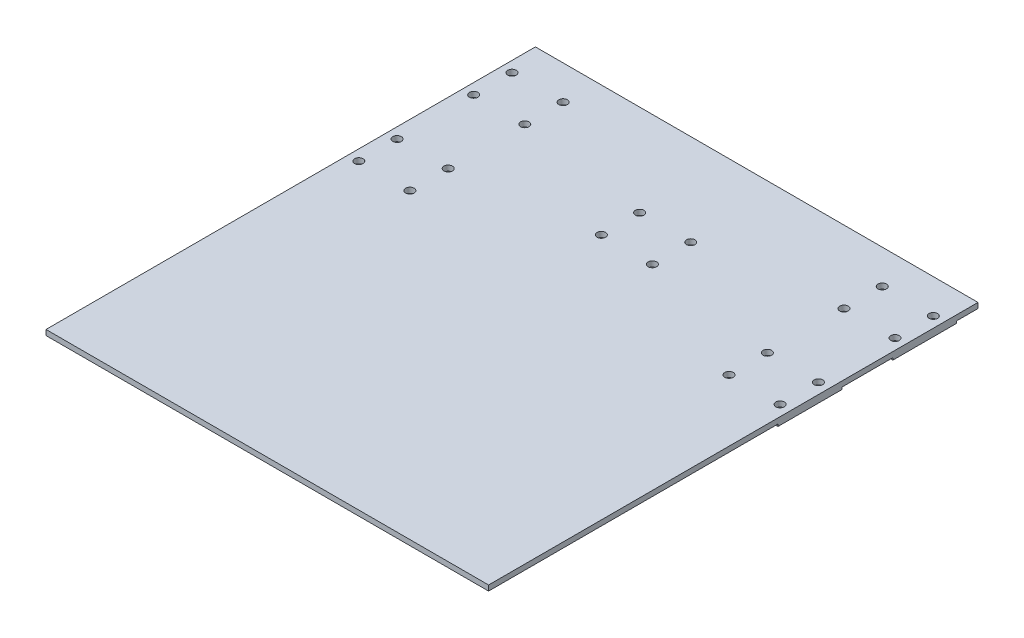
from build123d import *

# Parameters (mm, degrees)
CROQUIS1_W              = 208
CROQUIS1_H              = 365
SALIENTE_EXTRUIR1_DEPTH = 2.5
CROQUIS2_W              = 34
CROQUIS2_H              = 30
SALIENTE_EXTRUIR2_DEPTH = 1
CROQUIS3_W              = 208
CROQUIS3_H              = 135
CORTAR_EXTRUIR1_DEPTH   = 4.5
SKETCH1_R               = 2
CUT_EXTRUDE1_DEPTH      = 2.5


with BuildPart() as part:
    # Croquis1 → Saliente-Extruir1 (new body)
    with BuildSketch(Plane(origin=(0, 0, 0), x_dir=(1, 0, 0), z_dir=(0, 1, 0))):
        Rectangle(CROQUIS1_W, CROQUIS1_H)
    extrude(amount=SALIENTE_EXTRUIR1_DEPTH)

    # Croquis2 → Saliente-Extruir2 (add)
    with BuildSketch(Plane(origin=(0, 0, 0), x_dir=(-1, 0, 0), z_dir=(0, -1, 0))):
        with Locations((87, -31.5)):
            Rectangle(CROQUIS2_W, CROQUIS2_H)
        with Locations((-87, -31.5)):
            Rectangle(CROQUIS2_W, CROQUIS2_H)
        with Locations((-87, 22.5)):
            Rectangle(CROQUIS2_W, CROQUIS2_H)
        with Locations((87, 22.5)):
            Rectangle(CROQUIS2_W, CROQUIS2_H)
    extrude(amount=SALIENTE_EXTRUIR2_DEPTH)

    # Croquis3 → Cortar-Extruir1 (cut, through all)
    with BuildSketch(Plane(origin=(0, 2.5, 0), x_dir=(1, 0, 0), z_dir=(0, 1, 0))):
        with Locations((0, 115)):
            Rectangle(CROQUIS3_W, CROQUIS3_H)
    extrude(amount=-CORTAR_EXTRUIR1_DEPTH, mode=Mode.SUBTRACT)

    # Sketch1 → Cut-Extrude1 (cut)
    with BuildSketch(Plane.XZ):
        with Locations((-99, 40.5)):
            Circle(SKETCH1_R)
        with Locations((-75, 40.5)):
            Circle(SKETCH1_R)
        with Locations((-99, 22.5)):
            Circle(SKETCH1_R)
        with Locations((-75, 22.5)):
            Circle(SKETCH1_R)
        with Locations((-99, -13.5)):
            Circle(SKETCH1_R)
        with Locations((-99, -31.5)):
            Circle(SKETCH1_R)
        with Locations((-75, -31.5)):
            Circle(SKETCH1_R)
        with Locations((-75, -13.5)):
            Circle(SKETCH1_R)
        with Locations((75, -13.5)):
            Circle(SKETCH1_R)
        with Locations((75, -31.5)):
            Circle(SKETCH1_R)
        with Locations((99, -31.5)):
            Circle(SKETCH1_R)
        with Locations((99, -13.5)):
            Circle(SKETCH1_R)
        with Locations((99, 22.5)):
            Circle(SKETCH1_R)
        with Locations((75, 22.5)):
            Circle(SKETCH1_R)
        with Locations((75, 40.5)):
            Circle(SKETCH1_R)
        with Locations((99, 40.5)):
            Circle(SKETCH1_R)
        with Locations((-12, 13.5)):
            Circle(SKETCH1_R)
        with Locations((-12, -4.5)):
            Circle(SKETCH1_R)
        with Locations((12, -4.5)):
            Circle(SKETCH1_R)
        with Locations((12, 13.5)):
            Circle(SKETCH1_R)
    extrude(amount=-CUT_EXTRUDE1_DEPTH, mode=Mode.SUBTRACT)


solid = part.part
